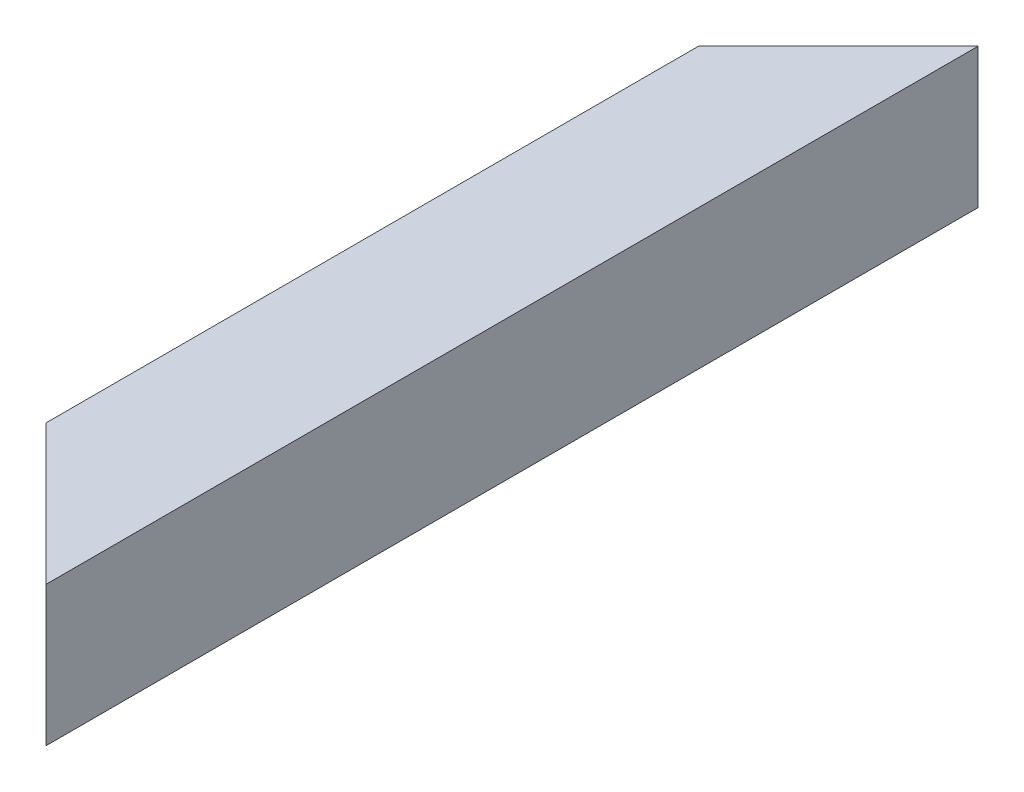
from build123d import *

# Parameters (mm, degrees)
SKETCH1_W          = 60
SKETCH1_H          = 60
SKETCH1_W_2        = 52
SKETCH1_H_2        = 52
CUT_EXTRUDE1_DEPTH = 61.0000001


with BuildPart() as part:
    # Sweep1: sweep along a curve in space
    with BuildLine() as sweep1_path:
        add(Edge.make_bspline(
            [(0, 0, 0), (0, 0, 400)],
            knots=[0, 0, 1, 1], degree=1))
    # Sketch1 → Sweep1 (sweep)
    with BuildSketch(Plane.XY):
        Rectangle(SKETCH1_W, SKETCH1_H)
        Rectangle(SKETCH1_W_2, SKETCH1_H_2, mode=Mode.SUBTRACT)
    sweep(path=sweep1_path.line)

    # Sketch2 → Cut-Extrude1 (cut, through all)
    with BuildSketch(Plane(origin=(0, 30, 0), x_dir=(1, 0, 0), z_dir=(0, 1, 0))):
        Polygon((30, 0), (-30, -60), (-30, 0), align=None)
        Polygon((30, -400), (-30, -340), (-30, -400), align=None)
    extrude(amount=-CUT_EXTRUDE1_DEPTH, mode=Mode.SUBTRACT)


solid = part.part
